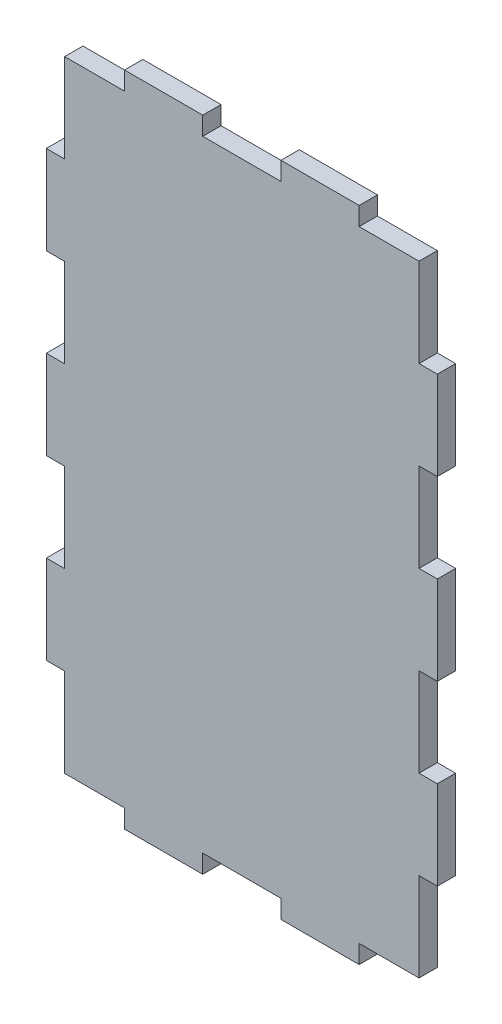
from build123d import *

# Parameters (mm, degrees)
SALIENTE_EXTRUIR1_DEPTH = 3


with BuildPart() as part:
    # Croquis1 → Saliente-Extruir1 (new body)
    with BuildSketch(Plane.XY):
        Polygon((-275.952144189, -257.710114598), (-285.752144189, -257.710114598), (-285.752144189, -243.194400312), (-288.752144189, -243.194400312), (-288.752144189, -228.678686026), (-285.752144189, -228.678686026), (-285.752144189, -214.162971741), (-288.752144189, -214.162971741), (-288.752144189, -199.647257455), (-285.752144189, -199.647257455), (-285.752144189, -185.131543169), (-288.752144189, -185.131543169), (-288.752144189, -170.615828883), (-285.752144189, -170.615828883), (-285.752144189, -156.100114598), (-275.952144189, -156.100114598), (-275.952144189, -153.100114598), (-263.152144189, -153.100114598), (-263.152144189, -156.100114598), (-250.352144189, -156.100114598), (-250.352144189, -153.100114598), (-237.552144189, -153.100114598), (-237.552144189, -156.100114598), (-227.752144189, -156.100114598), (-227.752144189, -170.615828883), (-224.752144189, -170.615828883), (-224.752144189, -185.131543169), (-227.752144189, -185.131543169), (-227.752144189, -199.647257455), (-224.752144189, -199.647257455), (-224.752144189, -214.162971741), (-227.752144189, -214.162971741), (-227.752144189, -228.678686026), (-224.752144189, -228.678686026), (-224.752144189, -243.194400312), (-227.752144189, -243.194400312), (-227.752144189, -257.710114598), (-237.552144189, -257.710114598), (-237.552144189, -260.710114598), (-250.352144189, -260.710114598), (-250.352144189, -257.710114598), (-263.152144189, -257.710114598), (-263.152144189, -260.710114598), (-275.952144189, -260.710114598), align=None)
    extrude(amount=SALIENTE_EXTRUIR1_DEPTH)


solid = part.part
